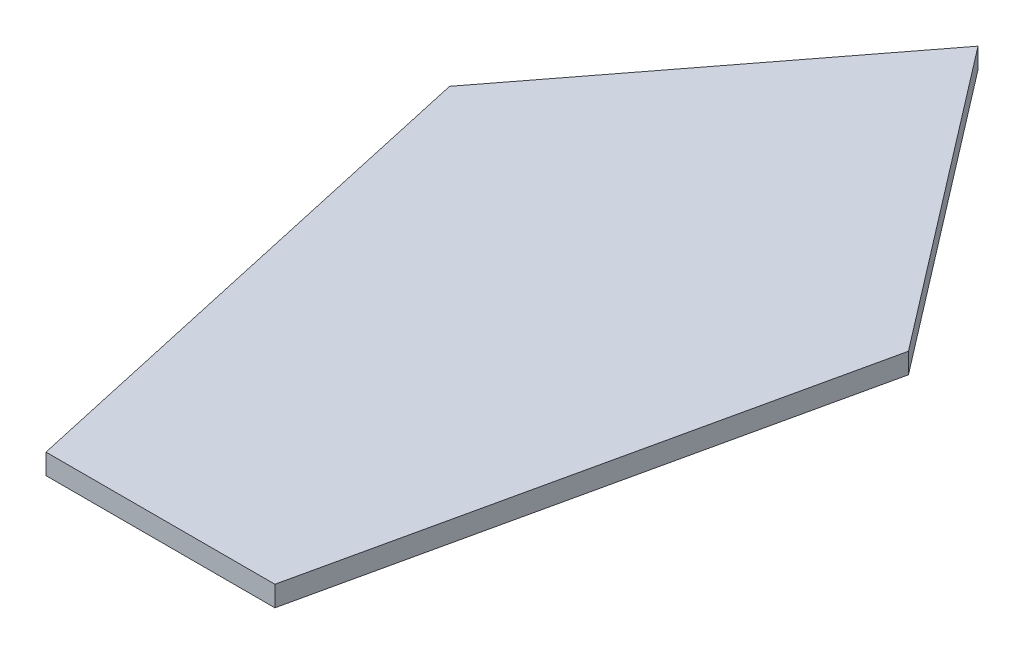
from build123d import *

# Parameters (mm, degrees)
BOSS_EXTRUDE1_DEPTH = 3.175


with BuildPart() as part:
    # Sketch1 → Boss-Extrude1 (new body)
    with BuildSketch(Plane(origin=(0, 0, 0), x_dir=(1, 0, 0), z_dir=(0, 1, 0))):
        Polygon((-17.78, 0), (17.78, 0), (35.638588535, 80.554887169), (0, 127), (-35.638588535, 80.554887169), align=None)
    extrude(amount=BOSS_EXTRUDE1_DEPTH)


solid = part.part
